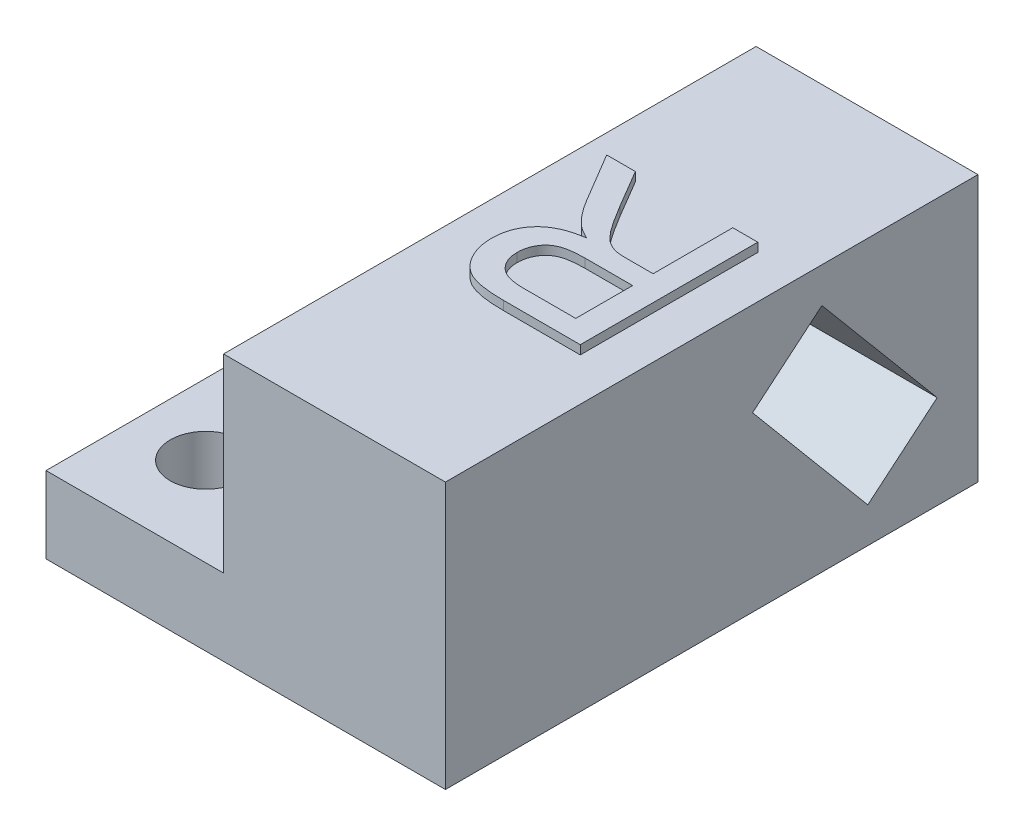
from build123d import *

# Parameters (mm, degrees)
SKETCH1_W           = 25
SKETCH1_H           = 60
BOSS_EXTRUDE1_DEPTH = 30
SKETCH2_W           = 60
SKETCH2_H           = 8.623813306
BOSS_EXTRUDE2_DEPTH = 20
SKETCH3_R           = 4
CUT_EXTRUDE1_DEPTH  = 9.623813306
CUT_EXTRUDE2_DEPTH  = 20
BOSS_EXTRUDE3_DEPTH = 1


with BuildPart() as part:
    # Sketch1 → Boss-Extrude1 (new body)
    with BuildSketch(Plane(origin=(0, 0, 0), x_dir=(1, 0, 0), z_dir=(0, 1, 0))):
        Rectangle(SKETCH1_W, SKETCH1_H)
    extrude(amount=BOSS_EXTRUDE1_DEPTH)

    # Sketch2 → Boss-Extrude2 (add)
    with BuildSketch(Plane.ZY.offset(12.5)):
        with Locations((0, 4.311906653)):
            Rectangle(SKETCH2_W, SKETCH2_H)
    extrude(amount=BOSS_EXTRUDE2_DEPTH)

    # Sketch3 → Cut-Extrude1 (cut, through all)
    with BuildSketch(Plane(origin=(0, 8.623813306, 0), x_dir=(1, 0, 0), z_dir=(0, 1, 0))):
        with Locations(Location((-24.5, 20, 0), (0, 0, 270))):  # turned: the seam where the file's is
            Circle(SKETCH3_R)
        with Locations(Location((-24.5, -20, 0), (0, 0, 270))):  # turned: the seam where the file's is
            Circle(SKETCH3_R)
    extrude(amount=-CUT_EXTRUDE1_DEPTH, mode=Mode.SUBTRACT)

    # Sketch4 → Cut-Extrude2 (cut)
    with BuildSketch(Plane(origin=(12.5, 0, 0), x_dir=(0, 0, -1), z_dir=(1, 0, 0))):
        Polygon((12.414671802, 26.015265685), (25.398981518, 10.541167934), (17.585328198, 3.984734315), (4.601018482, 19.458832066), align=None)
    extrude(amount=-CUT_EXTRUDE2_DEPTH, mode=Mode.SUBTRACT)

    # Sketch5 → Boss-Extrude3 (add)
    with BuildSketch(Plane(origin=(0, 30, 0), x_dir=(1, 0, 0), z_dir=(0, 1, 0))):
        with BuildLine():
            Line((7.692307692, 10), (7.692307692, -10))
            Line((7.692307692, -10), (-0.985576923, -10))
            add(Edge.make_bspline(
                [(-0.985576923, -10), (-1.189915508, -9.998406517), (-1.585388921, -9.995322517), (-2.158891161, -9.97328499), (-2.692933181, -9.926466249), (-3.190880742, -9.87417544), (-3.651881782, -9.796967041), (-4.076156001, -9.706387661), (-4.462076213, -9.599333368), (-4.812578849, -9.472790754), (-5.13779529, -9.329673653), (-5.439160579, -9.1529927), (-5.729614752, -8.959721513), (-5.997579665, -8.730765608), (-6.255124362, -8.484777239), (-6.491466209, -8.20944831), (-6.713599726, -7.911670049), (-6.98368474, -7.480457665), (-7.26734754, -6.902448182), (-7.511671117, -6.168093018), (-7.667028651, -5.399134972), (-7.683798939, -4.873873893), (-7.692307692, -4.607371795)],
                knots=[0, 0, 0, 0, 1.242075696, 2.40389213, 3.487198984, 4.500157661, 5.446319301, 6.326791195, 7.136300648, 7.878370406, 8.590488565, 9.292260633, 9.999224673, 10.708050372, 11.431369221, 12.162165018, 12.910600795, 13.687589445, 15.252257874, 16.810406251, 18.381693487, 20, 20, 20, 20], degree=3))
            add(Edge.make_bspline(
                [(-7.692307692, -4.607371795), (-7.688394011, -4.436288612), (-7.680664221, -4.098387595), (-7.621454116, -3.601582104), (-7.51431592, -3.126906532), (-7.376939813, -2.670193942), (-7.1888858, -2.237951011), (-6.971132957, -1.821215885), (-6.700987613, -1.431932834), (-6.399355855, -1.057091635), (-6.048612719, -0.71360816), (-5.658467411, -0.39614679), (-5.217190586, -0.123711561), (-4.739255324, 0.129469087), (-4.212344466, 0.337396306), (-3.644404331, 0.520482963), (-3.031039376, 0.661647942), (-2.605906991, 0.732754289), (-2.387820513, 0.769230769)],
                knots=[0, 0, 0, 0, 0.982645791, 1.940792824, 2.867691729, 3.775150443, 4.675643875, 5.571354211, 6.471357401, 7.392684514, 8.331098131, 9.285922955, 10.275520706, 11.304845665, 12.388884831, 13.524255008, 14.729980297, 16, 16, 16, 16], degree=3))
            add(Edge.make_bspline(
                [(-2.387820513, 0.769230769), (-2.549345996, 0.849743746), (-2.855664626, 1.002429402), (-3.272498706, 1.255059029), (-3.637663897, 1.492888205), (-3.845092801, 1.671226556), (-3.942307692, 1.754807692)],
                knots=[0, 0, 0, 0, 1.172551213, 2.223638478, 3.167479604, 4, 4, 4, 4], degree=3))
            add(Edge.make_bspline(
                [(-3.942307692, 1.754807692), (-4.131560958, 1.939760877), (-4.519688241, 2.319069404), (-5.049338611, 2.971134565), (-5.573421338, 3.688219618), (-5.888069662, 4.2107727), (-6.049679487, 4.479166667)],
                knots=[0, 0, 0, 0, 0.918170575, 1.883016652, 2.912673989, 4, 4, 4, 4], degree=3))
            Line((-6.049679487, 4.479166667), (-9.330929487, 10))
            Line((-9.330929487, 10), (-6.09775641, 10))
            Line((-6.09775641, 10), (-3.605769231, 5.77724359))
            add(Edge.make_bspline(
                [(-3.605769231, 5.77724359), (-3.516164402, 5.629086783), (-3.342524957, 5.34198322), (-3.091798881, 4.922621923), (-2.845639404, 4.536751784), (-2.618440056, 4.172360633), (-2.395792195, 3.839058208), (-2.196203285, 3.524230537), (-1.99576396, 3.245712753), (-1.765615132, 2.91110533), (-1.484546035, 2.549334189), (-1.156558274, 2.177690005), (-0.854995349, 1.869836465), (-0.473923576, 1.576103263), (-8.0808e-05, 1.307161834), (0.399436219, 1.179583217), (0.592948718, 1.117788462)],
                knots=[0, 0, 0, 0, 1.130591283, 2.190900266, 3.190104209, 4.119071823, 4.994606968, 5.807262858, 6.55236009, 7.234593472, 8.459046683, 9.540234366, 10.471327768, 11.266723835, 12.676093724, 14, 14, 14, 14], degree=3))
            add(Edge.make_bspline(
                [(0.592948718, 1.117788462), (0.674242958, 1.103128347), (0.859840146, 1.069658866), (1.174983707, 1.047799895), (1.556818794, 1.024599522), (1.833541189, 1.025275503), (1.983173077, 1.025641026)],
                knots=[0, 0, 0, 0, 0.709978628, 1.620902492, 2.713552433, 4, 4, 4, 4], degree=3))
            Line((1.983173077, 1.025641026), (4.871794872, 1.025641026))
            Line((4.871794872, 1.025641026), (4.871794872, 10))
            Line((4.871794872, 10), (7.692307692, 10))
        make_face()
        with BuildLine():
            Line((4.871794872, -1.282051282), (-0.484775641, -1.282051282))
            add(Edge.make_bspline(
                [(-0.484775641, -1.282051282), (-0.753386517, -1.286217416), (-1.255529355, -1.294005613), (-1.957518176, -1.361528247), (-2.558000395, -1.467075801), (-3.064646298, -1.627384754), (-3.490432782, -1.842070076), (-3.859462924, -2.104609449), (-4.169752828, -2.430321342), (-4.424939479, -2.80379836), (-4.624425797, -3.210810832), (-4.763816724, -3.641583566), (-4.857398907, -4.087856282), (-4.866967535, -4.393220511), (-4.871794872, -4.547275641)],
                knots=[0, 0, 0, 0, 1.546056516, 2.890207646, 4.055830773, 5.050253158, 5.937355789, 6.790906573, 7.644595853, 8.512568064, 9.38593768, 10.244184789, 11.114197691, 12, 12, 12, 12], degree=3))
            add(Edge.make_bspline(
                [(-4.871794872, -4.547275641), (-4.868088958, -4.659544766), (-4.86083016, -4.879447), (-4.822372143, -5.202097101), (-4.749202425, -5.50786025), (-4.648165007, -5.798940542), (-4.520236894, -6.075969951), (-4.363033481, -6.337858904), (-4.177365929, -6.583269781), (-3.964383478, -6.81341075), (-3.719926868, -7.02284832), (-3.440676061, -7.203538998), (-3.128860999, -7.357089463), (-2.784111469, -7.478956731), (-2.407515729, -7.576430897), (-1.996929252, -7.641277267), (-1.554229928, -7.688199899), (-1.24746496, -7.690912847), (-1.08974359, -7.692307692)],
                knots=[0, 0, 0, 0, 0.965235723, 1.89061323, 2.787065514, 3.661873922, 4.534873316, 5.404925039, 6.281839248, 7.175200054, 8.095223355, 9.040740021, 10.02630299, 11.075573487, 12.177989335, 13.364883635, 14.645170704, 16, 16, 16, 16], degree=3))
            Line((-1.08974359, -7.692307692), (4.871794872, -7.692307692))
            Line((4.871794872, -7.692307692), (4.871794872, -1.282051282))
        make_face(mode=Mode.SUBTRACT)
    extrude(amount=BOSS_EXTRUDE3_DEPTH)


solid = part.part
